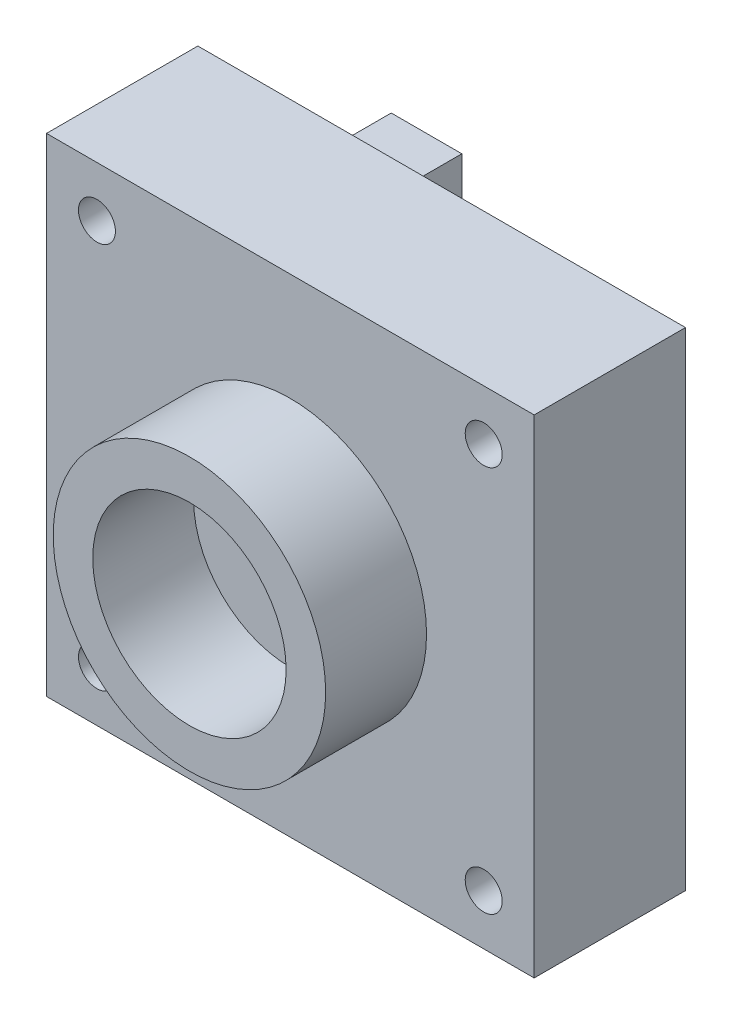
from build123d import *

# Parameters (mm, degrees)
SKETCH1_W           = 29
SKETCH1_H           = 29
BOSS_EXTRUDE1_DEPTH = 9
SKETCH3_R           = 8.1
BOSS_EXTRUDE2_DEPTH = 6
SKETCH4_R           = 5.75
CUT_EXTRUDE1_DEPTH  = 6
SKETCH5_R           = 1.1
CUT_EXTRUDE2_DEPTH  = 16
SKETCH6_R           = 1.1
BOSS_EXTRUDE3_DEPTH = 0.5
SKETCH7_R           = 2
SKETCH7_R_2         = 1.1
BOSS_EXTRUDE4_DEPTH = 1
SKETCH8_W           = 7.5
SKETCH8_H           = 13
BOSS_EXTRUDE5_DEPTH = 3
FILLET1_R           = 1
SKETCH9_W           = 1.5
SKETCH9_H           = 4
SKETCH9_H_2         = 6.5
CUT_EXTRUDE3_DEPTH  = 2
SKETCH10_W          = 4.2
SKETCH10_H          = 3.1
BOSS_EXTRUDE6_DEPTH = 4.6
SKETCH11_W          = 9
SKETCH11_H          = 9
SKETCH11_W_2        = 2.5
SKETCH11_H_2        = 1.5
SKETCH11_W_3        = 2
SKETCH11_H_3        = 3
BOSS_EXTRUDE7_DEPTH = 0.2
FILLET2_R           = 0.2


with BuildPart() as part:
    # Sketch1 → Boss-Extrude1 (new body)
    with BuildSketch(Plane.XY):
        with Locations((14.5, 14.5)):
            Rectangle(SKETCH1_W, SKETCH1_H)
    extrude(amount=BOSS_EXTRUDE1_DEPTH)

    # Sketch3 → Boss-Extrude2 (add)
    with BuildSketch(Plane.XY.offset(9)):
        with Locations((14.5, 14.5)):
            Circle(SKETCH3_R)
    extrude(amount=BOSS_EXTRUDE2_DEPTH)

    # Sketch4 → Cut-Extrude1 (cut)
    with BuildSketch(Plane.XY.offset(15)):
        with Locations((14.5, 14.5)):
            Circle(SKETCH4_R)
    extrude(amount=-CUT_EXTRUDE1_DEPTH, mode=Mode.SUBTRACT)

    # Sketch5 → Cut-Extrude2 (cut, through all)
    with BuildSketch(Plane(origin=(0, 0, 0), x_dir=(-1, 0, 0), z_dir=(0, 0, -1))):
        with Locations((-26, 26)):
            Circle(SKETCH5_R)
        with Locations((-3, 26)):
            Circle(SKETCH5_R)
        with Locations((-3, 3)):
            Circle(SKETCH5_R)
        with Locations((-26, 3)):
            Circle(SKETCH5_R)
    extrude(amount=-CUT_EXTRUDE2_DEPTH, mode=Mode.SUBTRACT)

    # Sketch6 → Boss-Extrude3 (add)
    with BuildSketch(Plane(origin=(0, 0, 0), x_dir=(-1, 0, 0), z_dir=(0, 0, -1))):
        Polygon((-28, 28), (-28, 1), (-1, 1), (-1, 8), (-7.5, 8), (-7.5, 21), (-1, 21), (-1, 28), align=None)
        with Locations((-26, 3)):
            Circle(SKETCH6_R, mode=Mode.SUBTRACT)
        with Locations((-3, 3)):
            Circle(SKETCH6_R, mode=Mode.SUBTRACT)
        with Locations((-3, 26)):
            Circle(SKETCH6_R, mode=Mode.SUBTRACT)
        with Locations((-26, 26)):
            Circle(SKETCH6_R, mode=Mode.SUBTRACT)
    extrude(amount=BOSS_EXTRUDE3_DEPTH)

    # Sketch7 → Boss-Extrude4 (add)
    with BuildSketch(Plane(origin=(0, 0, 0), x_dir=(-1, 0, 0), z_dir=(0, 0, -1))):
        with Locations((-26, 26)):
            Circle(SKETCH7_R)
        with Locations((-26, 26)):
            Circle(SKETCH7_R_2, mode=Mode.SUBTRACT)
        with Locations((-3, 26)):
            Circle(SKETCH7_R)
        with Locations((-3, 26)):
            Circle(SKETCH7_R_2, mode=Mode.SUBTRACT)
        with Locations((-3, 3)):
            Circle(SKETCH7_R)
        with Locations((-3, 3)):
            Circle(SKETCH7_R_2, mode=Mode.SUBTRACT)
        with Locations((-26, 3)):
            Circle(SKETCH7_R)
        with Locations((-26, 3)):
            Circle(SKETCH7_R_2, mode=Mode.SUBTRACT)
    extrude(amount=BOSS_EXTRUDE4_DEPTH)

    # Sketch10 → Boss-Extrude6 (add)
    with BuildSketch(Plane(origin=(0, 0, -0.5), x_dir=(-1, 0, 0), z_dir=(0, 0, -1))):
        with Locations((-8.5, 24.65)):
            Rectangle(SKETCH10_W, SKETCH10_H)
    extrude(amount=BOSS_EXTRUDE6_DEPTH)

    # Sketch11 → Boss-Extrude7 (add)
    with BuildSketch(Plane(origin=(0, 0, -0.5), x_dir=(-1, 0, 0), z_dir=(0, 0, -1))):
        with Locations((-18.5, 21.5)):
            Rectangle(SKETCH11_W, SKETCH11_H)
        with Locations((-22.5, 10.5)):
            Rectangle(SKETCH11_W, SKETCH11_H)
        with Locations((-25.75, 17.75)):
            Rectangle(SKETCH11_W_2, SKETCH11_H_2)
        with Locations((-25.75, 21)):
            Rectangle(SKETCH11_W_3, SKETCH11_H_3)
    extrude(amount=BOSS_EXTRUDE7_DEPTH)

    # Fillet2
    fillet2_edges = [part.edges().sort_by_distance(p)[0] for p in [
        (5, 3, -1),
        (28, 3, -1),
        (28, 26, -1),
        (5, 26, -1),
    ]]
    fillet(fillet2_edges, radius=FILLET2_R)


with BuildPart() as body_2:
    # Sketch8 → Boss-Extrude5 (new body)
    with BuildSketch(Plane(origin=(0, 0, 0), x_dir=(-1, 0, 0), z_dir=(0, 0, -1))):
        with Locations((-3.75, 14.5)):
            Rectangle(SKETCH8_W, SKETCH8_H)
    extrude(amount=BOSS_EXTRUDE5_DEPTH)

    # Fillet1
    fillet1_edges = [body_2.edges().sort_by_distance(p)[0] for p in [
        (3.75, 21, -3),
        (7.5, 14.5, -3),
        (3.75, 8, -3),
    ]]
    fillet(fillet1_edges, radius=FILLET1_R)

    # Sketch9 → Cut-Extrude3 (cut)
    with BuildSketch(Plane.ZY):
        with Locations((-1.5, 18.25)):
            Rectangle(SKETCH9_W, SKETCH9_H)
        with Locations((-1.5, 12)):
            Rectangle(SKETCH9_W, SKETCH9_H_2)
    extrude(amount=-CUT_EXTRUDE3_DEPTH, mode=Mode.SUBTRACT)


solid = Compound([part.part, body_2.part])
